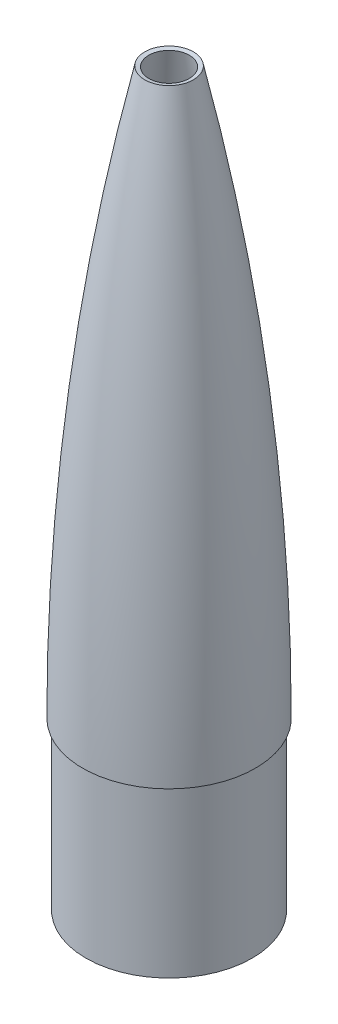
from build123d import *


with BuildPart() as part:
    # Sketch1 → Revolve-Thin3 (revolve)
    with BuildSketch(Plane.XY):
        with BuildLine():
            ThreePointArc((18.551548743, 431.8), (54.132203955, 217.201745506), (66.04, 0))
            Line((66.04, 0), (63.5, 0))
            Line((63.5, 0), (63.5, -127))
            Line((63.5, -127), (60.325, -127))
            Line((60.325, -127), (60.325, 3.175))
            Line((60.325, 3.175), (62.862459123, 3.175))
            ThreePointArc((62.862459123, 3.175), (50.80205754, 218.432575212), (15.452434998, 431.109986233))
            Line((15.452434998, 431.109986233), (18.551548743, 431.8))
        make_face()
    revolve(axis=Axis((0, 0, 0), (0, 1, 0)))


solid = part.part
